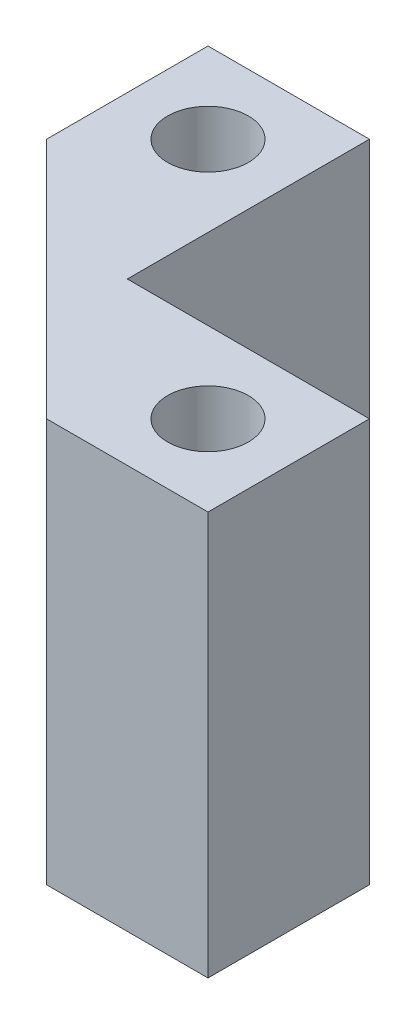
from build123d import *

# Parameters (mm, degrees)
SKETCH1_R           = 2.5
BOSS_EXTRUDE1_DEPTH = 25


with BuildPart() as part:
    # Sketch1 → Boss-Extrude1 (new body)
    with BuildSketch(Plane(origin=(0, 0, 0), x_dir=(1, 0, 0), z_dir=(0, 1, 0))):
        Polygon((5, 5), (5, 20), (-5, 20), (-5, 10), (10, -5), (20, -5), (20, 5), align=None)
        with Locations((0, 15)):
            Circle(SKETCH1_R, mode=Mode.SUBTRACT)
        with Locations((15, 0)):
            Circle(SKETCH1_R, mode=Mode.SUBTRACT)
    extrude(amount=BOSS_EXTRUDE1_DEPTH)


solid = part.part
